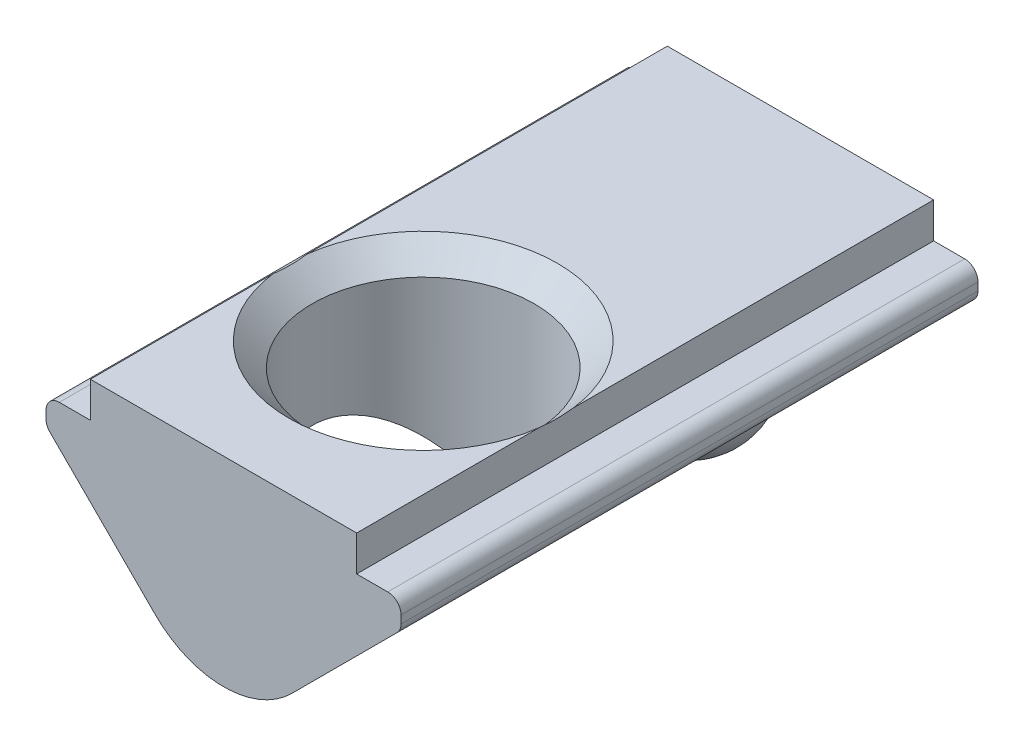
from build123d import *

# Parameters (mm, degrees)
EXTRUDE_1_DEPTH             = 6.5
HOLE_WIZARD_M61_D           = 5
HOLE_WIZARD_M61_CSINK_D     = 6.05
HOLE_WIZARD_M61_CSINK_ANGLE = 90
FILLET_1_R                  = 0.3


with BuildPart() as part:
    # Эскиз1 → Бобышка-Вытянуть1 (new body, symmetric)
    with BuildSketch(Plane.XY):
        with BuildLine():
            Line((-3, 0), (3, 0))
            Line((3, 0), (3, -0.8))
            Line((3, -0.8), (4, -0.8))
            Line((4, -0.8), (4, -1.4))
            Line((4, -1.4), (1.536396103, -3.863603897))
            ThreePointArc((1.536396103, -3.863603897), (0, -4.5), (-1.536396103, -3.863603897))
            Line((-1.536396103, -3.863603897), (-4, -1.4))
            Line((-4, -1.4), (-4, -0.8))
            Line((-4, -0.8), (-3, -0.8))
            Line((-3, -0.8), (-3, 0))
        make_face()
    extrude(amount=EXTRUDE_1_DEPTH, both=True)

    # Отверстие обработанное метчиком M61 (through all)
    with Locations(Plane(origin=(0, 0, 0), x_dir=(1, 0, 0), z_dir=(0, 1, 0))):
        with Locations((0, -2)):
            CounterSinkHole(HOLE_WIZARD_M61_D / 2, HOLE_WIZARD_M61_CSINK_D / 2, counter_sink_angle=HOLE_WIZARD_M61_CSINK_ANGLE)

    # Эскиз5 → Повернуть1 (revolve)
    with BuildSketch(Plane(origin=(0, 0, 0), x_dir=(0, 0, -1), z_dir=(1, 0, 0))):
        with BuildLine():
            Line((4, -2), (4, -5))
            ThreePointArc((4, -5), (2.5, -3.5), (4, -2))
        make_face()
    revolve(axis=Axis((0, -2, -4), (0, -1, 0)))

    # Скругление1
    fillet_1_edges = [part.edges().sort_by_distance(p)[0] for p in [
        (4, -0.8, 0),
        (4, -1.4, 0),
        (-4, -1.4, 0),
        (-4, -0.8, 0),
    ]]
    fillet(fillet_1_edges, radius=FILLET_1_R)


solid = part.part
